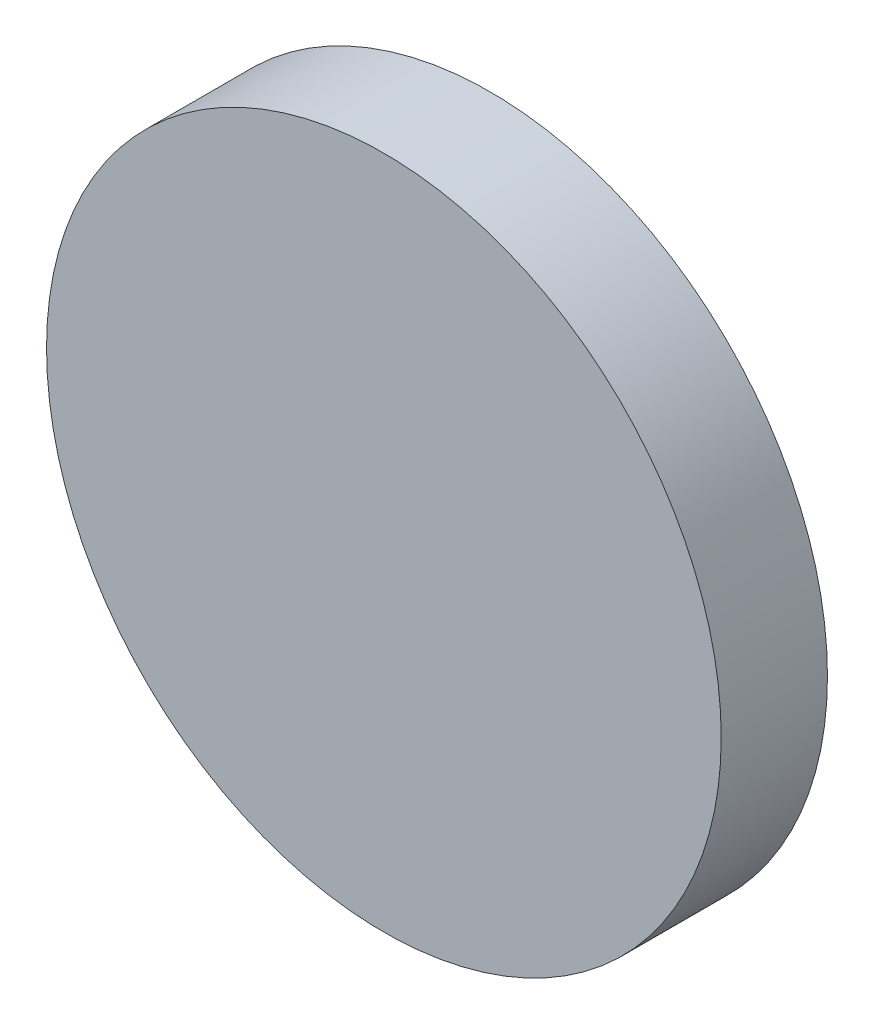
from build123d import *

# Parameters (mm, degrees)
SKETCH_1_R      = 12.7
EXTRUDE_1_DEPTH = 4


with BuildPart() as part:
    # 草图1 → 凸台-拉伸1 (new body)
    with BuildSketch(Plane.XY):
        Circle(SKETCH_1_R)
    extrude(amount=EXTRUDE_1_DEPTH)


solid = part.part
